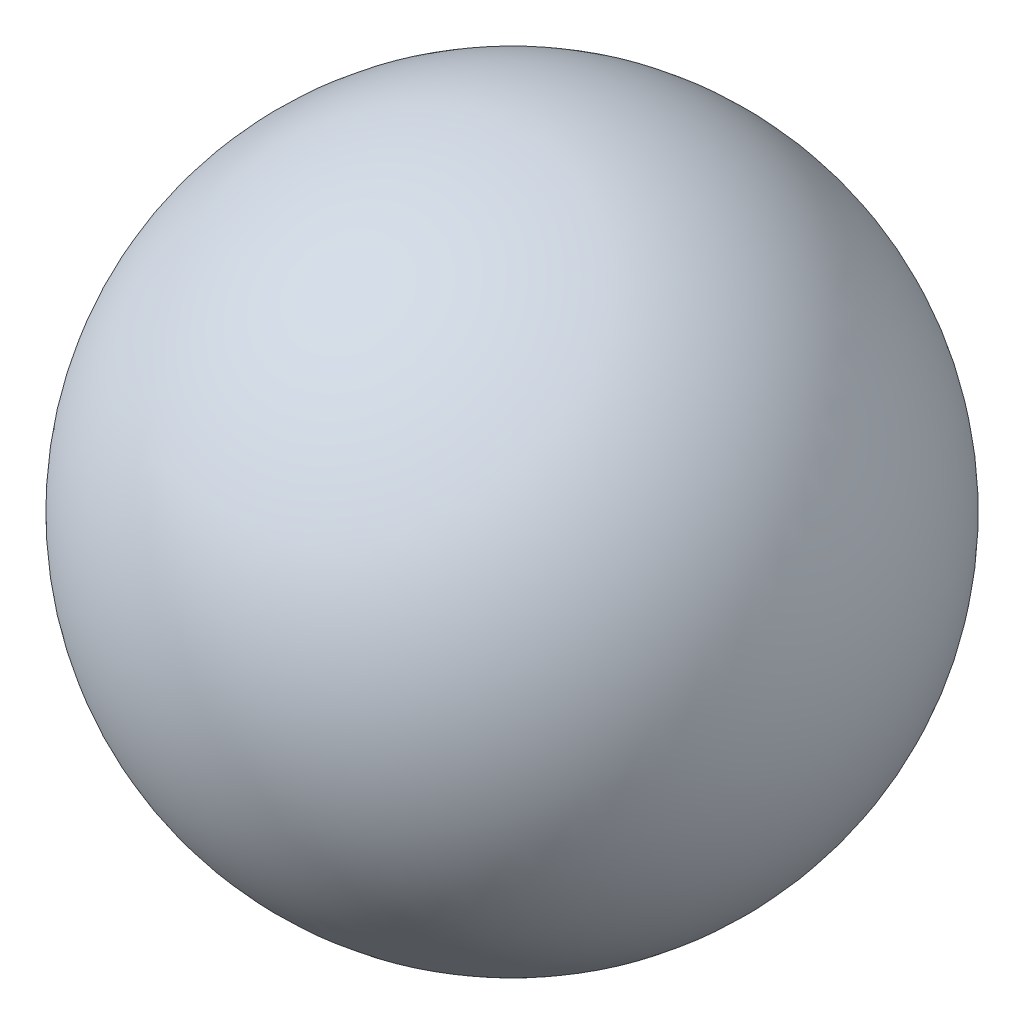
from build123d import *


with BuildPart() as part:
    # Sketch1 → Revolve2 (revolve)
    with BuildSketch(Plane.XY):
        with BuildLine():
            Line((0, 1.65), (0, -1.65))
            ThreePointArc((0, -1.65), (-1.65, 0), (0, 1.65))
        make_face()
    revolve(axis=Axis((0, 1.65, 0), (0, -1, 0)))


solid = part.part
